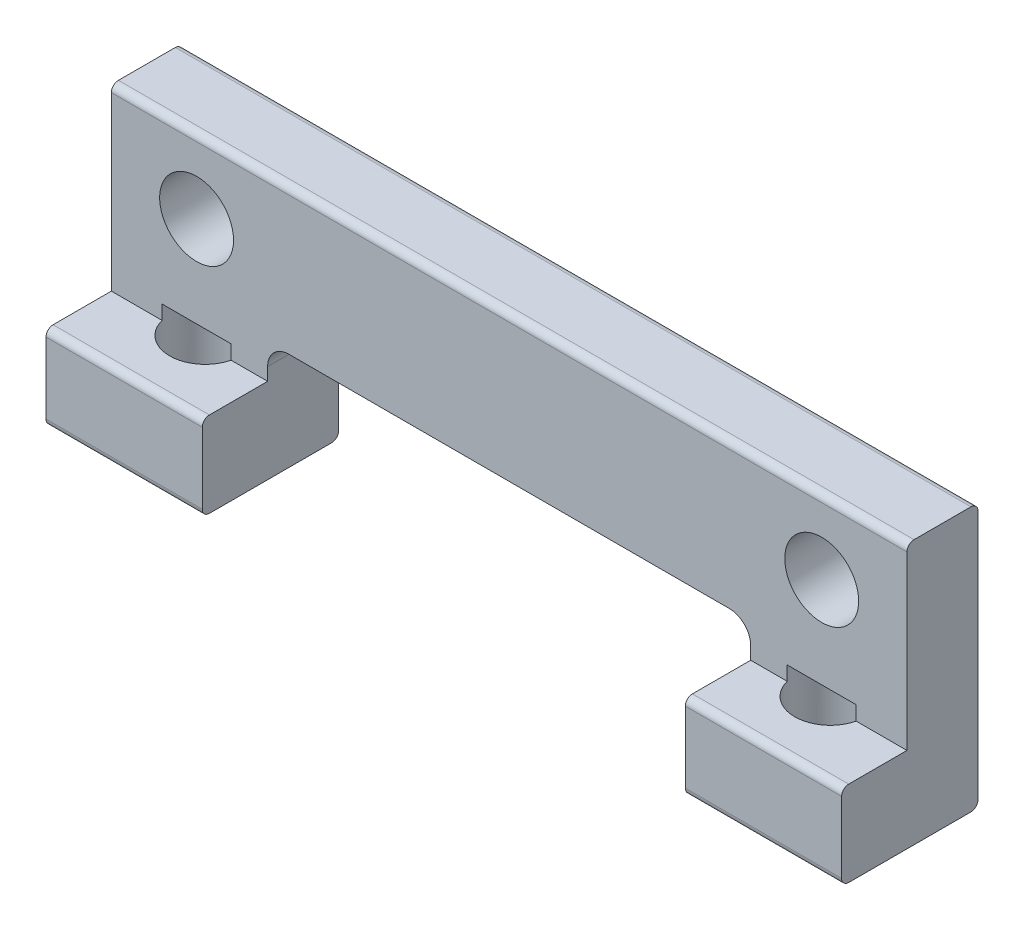
from build123d import *

# Parameters (mm, degrees)
SKETCH_1_W               = 28
SKETCH_1_H               = 9.3
EXTRUDE_1_DEPTH          = 4.8
SKETCH_2_W               = 28
SKETCH_2_H               = 6.3
CUT_EXTRUDE_1_DEPTH      = 2.3
SKETCH_4_W               = 17
SKETCH_4_H               = 4.2
CUT_EXTRUDE_2_DEPTH      = 1
CUT_EXTRUDE_2_DEPTH_BACK = 5.8
SKETCH_5_R               = 1.3
CUT_EXTRUDE_3_DEPTH      = 3.5
FILLET_1_R               = 0.75
SKETCH_6_R               = 1.25
CUT_EXTRUDE_4_DEPTH      = 3.5
FILLET_2_R               = 0.25


with BuildPart() as part:
    # 스케치1 → 보스-돌출1 (new body)
    with BuildSketch(Plane.XY):
        with Locations((14, 4.65)):
            Rectangle(SKETCH_1_W, SKETCH_1_H)
    extrude(amount=EXTRUDE_1_DEPTH)

    # 스케치2 → 컷-돌출1 (cut)
    with BuildSketch(Plane.XY.offset(4.8)):
        with Locations((14, 6.15)):
            Rectangle(SKETCH_2_W, SKETCH_2_H)
    extrude(amount=-CUT_EXTRUDE_1_DEPTH, mode=Mode.SUBTRACT)

    # 스케치4 → 컷-돌출2 (cut, two sides)
    with BuildSketch(Plane.XY.offset(4.8)) as cut_extrude_2_sk:
        with Locations((14, 2.1)):
            Rectangle(SKETCH_4_W, SKETCH_4_H)
    extrude(amount=CUT_EXTRUDE_2_DEPTH, mode=Mode.SUBTRACT)
    extrude(cut_extrude_2_sk.sketch, amount=-CUT_EXTRUDE_2_DEPTH_BACK, mode=Mode.SUBTRACT)

    # 스케치5 → 컷-돌출3 (cut, through all)
    with BuildSketch(Plane.XY.offset(2.5)):
        with Locations((3, 6.7)):
            Circle(SKETCH_5_R)
        with Locations((25, 6.7)):
            Circle(SKETCH_5_R)
    extrude(amount=-CUT_EXTRUDE_3_DEPTH, mode=Mode.SUBTRACT)

    # 필렛1
    fillet_1_edges = [part.edges().sort_by_distance(p)[0] for p in [
        (5.5, 4.2, 1.25),
        (22.5, 4.2, 1.25),
    ]]
    fillet(fillet_1_edges, radius=FILLET_1_R)

    # 스케치6 → 컷-돌출4 (cut)
    with BuildSketch(Plane.XZ):
        with Locations((3, 2.2)):
            Circle(SKETCH_6_R)
        with Locations((25, 2.2)):
            Circle(SKETCH_6_R)
    extrude(amount=-CUT_EXTRUDE_4_DEPTH, mode=Mode.SUBTRACT)

    # 필렛2
    fillet_2_edges = [part.edges().sort_by_distance(p)[0] for p in [
        (14, 9.3, 2.5),
        (2.75, 3, 4.8),
        (25.25, 3, 4.8),
        (25.25, 0, 0),
        (25.25, 0, 4.8),
        (14, 9.3, 0),
        (2.75, 0, 0),
        (2.75, 0, 4.8),
    ]]
    fillet(fillet_2_edges, radius=FILLET_2_R)


solid = part.part
